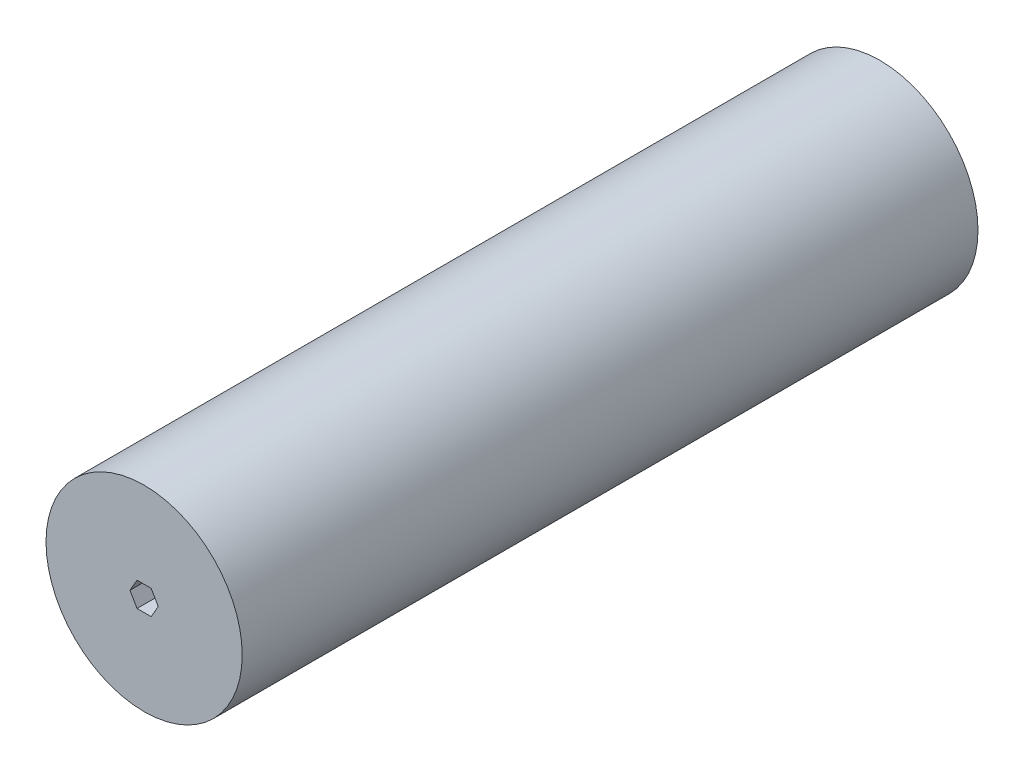
from build123d import *

# Parameters (mm, degrees)
SKETCH1_R               = 50.8
BOSS_EXTRUDE1_DEPTH     = 381
CUT_EXTRUDE1_DEPTH      = 1
CUT_EXTRUDE1_DEPTH_BACK = 382


with BuildPart() as part:
    # Sketch1 → Boss-Extrude1 (new body)
    with BuildSketch(Plane.XY):
        Circle(SKETCH1_R)
    extrude(amount=BOSS_EXTRUDE1_DEPTH)

    # Sketch2 → Cut-Extrude1 (cut, two sides)
    with BuildSketch(Plane.XY.offset(381)) as cut_extrude1_sk:
        Polygon((3.666174209, 6.35), (-3.666174209, 6.35), (-7.332348419, 0), (-3.666174209, -6.35), (3.666174209, -6.35), (7.332348419, 0), align=None)
    extrude(amount=CUT_EXTRUDE1_DEPTH, mode=Mode.SUBTRACT)
    extrude(cut_extrude1_sk.sketch, amount=-CUT_EXTRUDE1_DEPTH_BACK, mode=Mode.SUBTRACT)


solid = part.part
